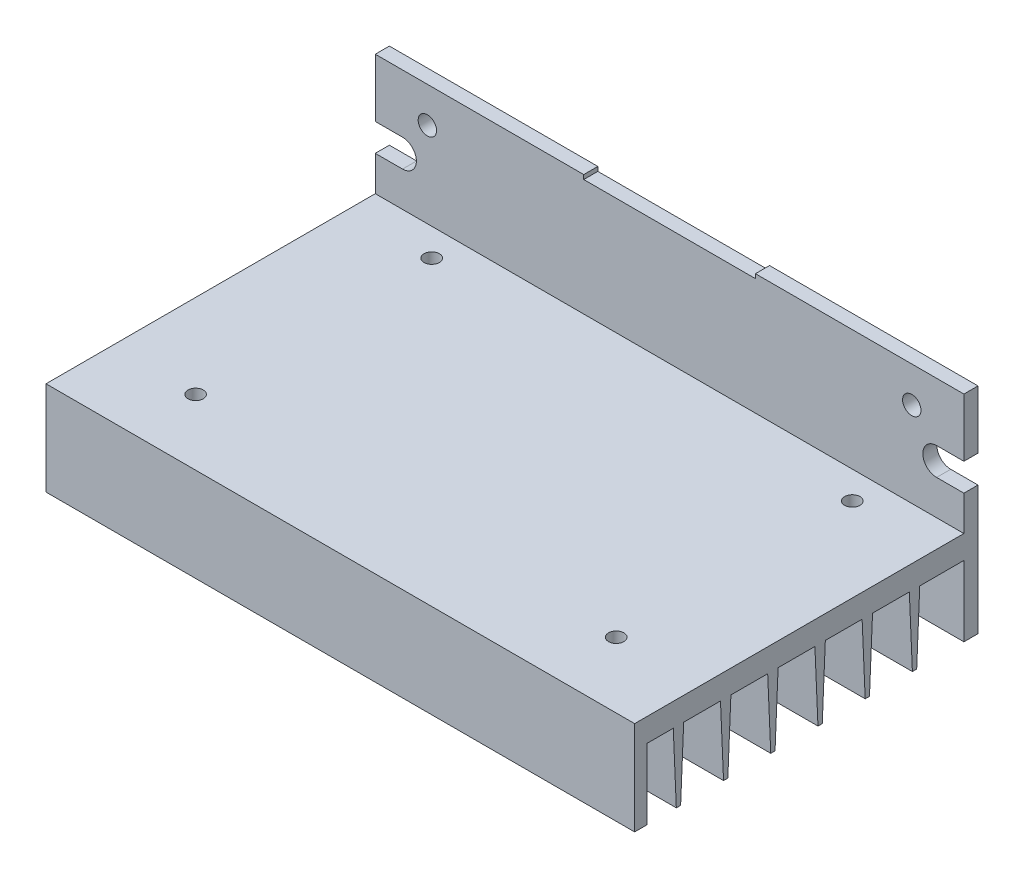
from build123d import *

# Parameters (mm, degrees)
SKETCH1_W             = 96
SKETCH1_H             = 56
BOSS_EXTRUDE1_DEPTH   = 3.8
SKETCH2_W             = 96
SKETCH2_H             = 35
BOSS_EXTRUDE2_DEPTH   = 2.3
CUT_EXTRUDE1_DEPTH    = 3.3
SKETCH4_R             = 1.5
CUT_EXTRUDE2_DEPTH    = 3.3
SKETCH5_W             = 96
SKETCH5_H             = 2
BOSS_EXTRUDE3_DEPTH   = 11.5
BOSS_EXTRUDE5_DEPTH   = 48
LPATTERN1_COUNT       = 6
LPATTERN1_PITCH       = 7.7
SKETCH8_W             = 28
SKETCH8_H             = 2.3
CUT_EXTRUDE3_DEPTH    = 0.7
M3X0_5_TAPPED_HOLE1_D = 2.5
LPATTERN2_COUNT       = 2
LPATTERN2_PITCH       = 38.5


with BuildPart() as part:
    # Sketch1 → Boss-Extrude1 (new body)
    with BuildSketch(Plane(origin=(0, 0, 0), x_dir=(1, 0, 0), z_dir=(0, 1, 0))):
        Rectangle(SKETCH1_W, SKETCH1_H)
    extrude(amount=BOSS_EXTRUDE1_DEPTH)

    # Sketch2 → Boss-Extrude2 (add)
    with BuildSketch(Plane(origin=(0, 0, -28), x_dir=(-1, 0, 0), z_dir=(0, 0, -1))):
        with Locations((0, 6)):
            Rectangle(SKETCH2_W, SKETCH2_H)
    extrude(amount=-BOSS_EXTRUDE2_DEPTH)

    # Sketch3 → Cut-Extrude1 (cut, through all)
    with BuildSketch(Plane(origin=(0, 0, -25.7), x_dir=(-1, 0, 0), z_dir=(0, 0, -1))):
        with BuildLine():
            Line((-52.45, 14), (-43.55, 14))
            ThreePointArc((-43.55, 14), (-41.3, 11.75), (-43.55, 9.5))
            Line((-43.55, 9.5), (-52.45, 9.5))
            ThreePointArc((-52.45, 9.5), (-54.7, 11.75), (-52.45, 14))
        make_face()
    cut_extrude1 = extrude(amount=CUT_EXTRUDE1_DEPTH, mode=Mode.SUBTRACT)

    # Sketch4 → Cut-Extrude2 (cut, through all)
    with BuildSketch(Plane.XY.offset(-25.7)):
        with Locations((39.5, 17.7)):
            Circle(SKETCH4_R)
    cut_extrude2 = extrude(amount=-CUT_EXTRUDE2_DEPTH, mode=Mode.SUBTRACT)

    # Mirror1: Cut-Extrude1, Cut-Extrude2 across plane
    add(cut_extrude1.mirror(Plane(origin=(0, 0, 0), x_dir=(0, 0, 1), z_dir=(1, 0, 0))), mode=Mode.SUBTRACT)
    add(cut_extrude2.mirror(Plane(origin=(0, 0, 0), x_dir=(0, 0, 1), z_dir=(1, 0, 0))), mode=Mode.SUBTRACT)

    # Sketch5 → Boss-Extrude3 (add)
    with BuildSketch(Plane(origin=(0, 0, 0), x_dir=(1, 0, 0), z_dir=(0, 1, 0))):
        with Locations((0, -27)):
            Rectangle(SKETCH5_W, SKETCH5_H)
    extrude(amount=-BOSS_EXTRUDE3_DEPTH)

    # Sketch7 → Boss-Extrude5 (add, symmetric)
    with BuildSketch(Plane(origin=(0, 0, 0), x_dir=(0, 0, -1), z_dir=(1, 0, 0))):
        Polygon((-21.7, 0), (-21.2, -11.5), (-20.5, -11.5), (-20, 0), align=None)
    boss_extrude5 = extrude(amount=BOSS_EXTRUDE5_DEPTH, both=True)

    # LPattern1: Boss-Extrude5 ×6
    with Locations(*[(0, 0, -i * LPATTERN1_PITCH) for i in range(1, LPATTERN1_COUNT)]):
        add(boss_extrude5)

    # Sketch8 → Cut-Extrude3 (cut)
    with BuildSketch(Plane(origin=(0, 23.5, 0), x_dir=(1, 0, 0), z_dir=(0, 1, 0))):
        with Locations((0, 26.85)):
            Rectangle(SKETCH8_W, SKETCH8_H)
    extrude(amount=-CUT_EXTRUDE3_DEPTH, mode=Mode.SUBTRACT)

    # M3x0.5 Tapped Hole1 (through all)
    with Locations(Plane(origin=(0, 3.8, 0), x_dir=(1, 0, 0), z_dir=(0, 1, 0))):
        with Locations((-34.3, -17.3), (34.3, -17.3)):
            m3x0_5_tapped_hole1 = Hole(M3X0_5_TAPPED_HOLE1_D / 2)

    # LPattern2: M3x0.5 Tapped Hole1 ×2
    with Locations(*[(0, 0, -i * LPATTERN2_PITCH) for i in range(1, LPATTERN2_COUNT)]):
        add(m3x0_5_tapped_hole1, mode=Mode.SUBTRACT)


solid = part.part
